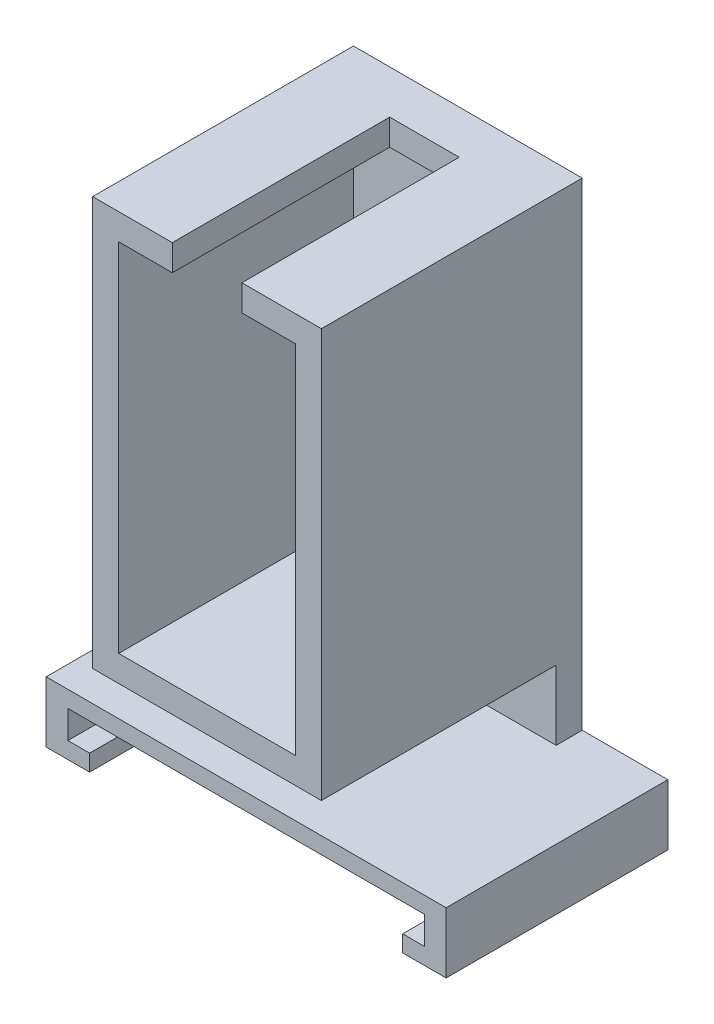
from build123d import *

# Parameters (mm, degrees)
SKETCH1_W           = 20.31
SKETCH1_H           = 41
BOSS_EXTRUDE1_DEPTH = 3
SKETCH2_W           = 26.31
SKETCH2_H           = 47
SKETCH2_W_2         = 20.31
SKETCH2_H_2         = 41
BOSS_EXTRUDE2_DEPTH = 5
SKETCH3_W           = 26.31
SKETCH3_H           = 8
BOSS_EXTRUDE3_DEPTH = 3
SKETCH4_W           = 46
SKETCH4_H           = 1.9
BOSS_EXTRUDE4_DEPTH = 5.5
SKETCH5_W           = 46
SKETCH5_H           = 3.2
BOSS_EXTRUDE5_DEPTH = 3
BOSS_EXTRUDE6_DEPTH = 5
SKETCH8_W           = 2.5
SKETCH8_H           = 3.2
BOSS_EXTRUDE7_DEPTH = 2.5
BOSS_EXTRUDE8_DEPTH = 20
BOSS_EXTRUDE9_DEPTH = 20


with BuildPart() as part:
    # Sketch1 → Boss-Extrude1 (new body)
    with BuildSketch(Plane.XY):
        Rectangle(SKETCH1_W, SKETCH1_H)
    extrude(amount=BOSS_EXTRUDE1_DEPTH)

    # Sketch2 → Boss-Extrude2 (add)
    with BuildSketch(Plane(origin=(0, 0, 0), x_dir=(-1, 0, 0), z_dir=(0, 0, -1))):
        Rectangle(SKETCH2_W, SKETCH2_H)
        Rectangle(SKETCH2_W_2, SKETCH2_H_2, mode=Mode.SUBTRACT)
    extrude(amount=-BOSS_EXTRUDE2_DEPTH)

    # Sketch3 → Boss-Extrude3 (add)
    with BuildSketch(Plane(origin=(0, 0, 0), x_dir=(-1, 0, 0), z_dir=(0, 0, -1))):
        with Locations((0, -27.5)):
            Rectangle(SKETCH3_W, SKETCH3_H)
    extrude(amount=-BOSS_EXTRUDE3_DEPTH)

    # Sketch4 → Boss-Extrude4 (add)
    with BuildSketch(Plane(origin=(0, 0, 0), x_dir=(-1, 0, 0), z_dir=(0, 0, -1))):
        with Locations((0, -37.55)):
            Rectangle(SKETCH4_W, SKETCH4_H)
        Polygon((13.155, -31.5), (0, -31.5), (-13.155, -31.5), (-23, -31.5), (-23, -33.4), (23, -33.4), (23, -31.5), align=None)
    extrude(amount=-BOSS_EXTRUDE4_DEPTH)


with BuildPart() as boss_extrude4_piece_1:
    # of the separate pieces the step leaves, piece 1, a body of its own (boss_extrude4_pieces)
    add(part.part.solids().sort_by_distance((-13.155, -31.5, 0))[0])



with BuildPart() as boss_extrude4_piece_2:
    # of the separate pieces the step leaves, piece 2, a body of its own (boss_extrude4_pieces)
    add(part.part.solids().sort_by_distance((-23, -38.5, 0))[0])


with BuildPart() as boss_extrude4_piece_1_1:
    add(boss_extrude4_piece_1.part)

    add(boss_extrude4_piece_2.part)  # Boss-Extrude5 merges Boss-Extrude4 piece 2
    # Sketch5 → Boss-Extrude5 (add)
    with BuildSketch(Plane(origin=(0, 0, 0), x_dir=(-1, 0, 0), z_dir=(0, 0, -1))):
        with Locations((0, -35)):
            Rectangle(SKETCH5_W, SKETCH5_H)
    extrude(amount=-BOSS_EXTRUDE5_DEPTH)

    # Sketch6 → Boss-Extrude6 (add)
    with BuildSketch(Plane.XY.offset(5)):
        Polygon((4.010497469, 23.5), (4.010497469, 20.5), (10.155, 20.5), (10.155, -20.5), (-10.155, -20.5), (-10.155, 20.5), (-3.989502531, 20.5), (-3.989502531, 23.5), (-13.155, 23.5), (-13.155, -23.5), (13.155, -23.5), (13.155, 23.5), align=None)
    extrude(amount=BOSS_EXTRUDE6_DEPTH)

    # Sketch8 → Boss-Extrude7 (add)
    with BuildSketch(Plane.XY.offset(3)):
        with Locations((-21.75, -35)):
            Rectangle(SKETCH8_W, SKETCH8_H)
        with Locations((21.75, -35)):
            Rectangle(SKETCH8_W, SKETCH8_H)
    extrude(amount=BOSS_EXTRUDE7_DEPTH)

    # Sketch9 → Boss-Extrude8 (add)
    with BuildSketch(Plane.XY.offset(5.5)):
        Polygon((-23, -31.5), (-23, -38.5), (-18, -38.5), (-18, -36.6), (-20.5, -36.6), (-20.5, -33.4), (20.5, -33.4), (20.5, -36.6), (18, -36.6), (18, -38.5), (23, -38.5), (23, -31.5), align=None)
    extrude(amount=BOSS_EXTRUDE8_DEPTH)

    # Sketch12 → Boss-Extrude9 (add)
    with BuildSketch(Plane.XY.offset(10)):
        Polygon((13.155, -23.5), (13.155, 23.5), (4.010497469, 23.5), (4.010497469, 20.5), (10.155, 20.5), (10.155, -20.5), (-10.155, -20.5), (-10.155, 20.5), (-3.989502531, 20.5), (-3.989502531, 23.5), (-13.155, 23.5), (-13.155, -23.5), align=None)
    extrude(amount=BOSS_EXTRUDE9_DEPTH)


solid = boss_extrude4_piece_1_1.part
